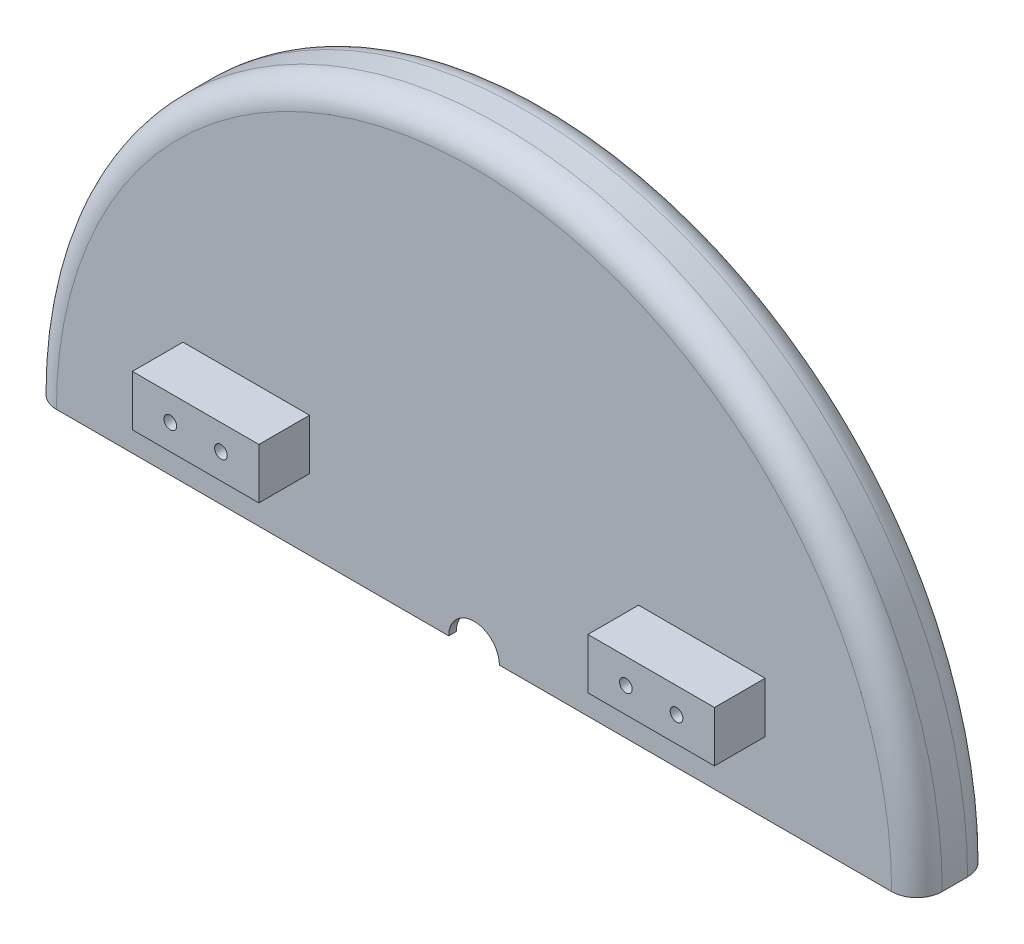
from build123d import *

# Parameters (mm, degrees)
SKETCH1_R                    = 175
BOSS_EXTRUDE3_DEPTH          = 30
CUT_EXTRUDE1_DEPTH           = 50
SHELL2_T                     = -3
SKETCH4_R                    = 10
CUT_EXTRUDE2_DEPTH           = 50
FILLET1_R                    = 10
SKETCH6_R                    = 50
CUT_EXTRUDE4_DEPTH           = 10
SKETCH9_W                    = 50
SKETCH9_H                    = 20
BOSS_EXTRUDE4_DEPTH          = 20
F_5_0_5_DIAMETER_HOLE2_D     = 5
F_5_0_5_DIAMETER_HOLE2_DEPTH = 11
F_5_0_5_DIAMETER_HOLE2_TIP   = 1.502151548


with BuildPart() as part:
    # Sketch1 → Boss-Extrude3 (new body)
    with BuildSketch(Plane.XY):
        Circle(SKETCH1_R)
    extrude(amount=BOSS_EXTRUDE3_DEPTH)

    # Sketch3 → Cut-Extrude1 (cut)
    with BuildSketch(Plane.XY.offset(30)):
        with BuildLine():
            Line((-175, 0), (175, 0))
            ThreePointArc((175, 0), (0, -175), (-175, 0))
        make_face()
    extrude(amount=-CUT_EXTRUDE1_DEPTH, mode=Mode.SUBTRACT)

    # Shell2
    shell2_openings = [part.faces().sort_by_distance(p)[0] for p in [
        (0, 0, 15),
    ]]
    offset(amount=SHELL2_T, openings=shell2_openings)

    # Sketch4 → Cut-Extrude2 (cut)
    with BuildSketch(Plane.XY.offset(30)):
        Circle(SKETCH4_R)
    extrude(amount=-CUT_EXTRUDE2_DEPTH, mode=Mode.SUBTRACT)

    # Fillet1
    fillet1_edges = [part.edges().sort_by_distance(p)[0] for p in [
        (0, 175, 0),
        (0, 175, 30),
    ]]
    fillet(fillet1_edges, radius=FILLET1_R)

    # Sketch6 → Cut-Extrude4 (cut)
    with BuildSketch(Plane(origin=(0, 0, 0), x_dir=(-1, 0, 0), z_dir=(0, 0, -1))):
        Circle(SKETCH6_R)
    extrude(amount=-CUT_EXTRUDE4_DEPTH, mode=Mode.SUBTRACT)

    # Sketch9 → Boss-Extrude4 (add)
    with BuildSketch(Plane.XY.offset(30)):
        with Locations((-90, 38)):
            Rectangle(SKETCH9_W, SKETCH9_H)
    boss_extrude4 = extrude(amount=BOSS_EXTRUDE4_DEPTH)

    # Mirror2: Boss-Extrude4 across plane
    add(boss_extrude4.mirror(Plane(origin=(0, 0, 0), x_dir=(0, 0, 1), z_dir=(1, 0, 0))))

    # Ø5.0 (5) Diameter Hole2
    with Locations(Plane.XY.offset(50)):
        with Locations((-100, 38), (-80, 38), (80, 38), (100, 38)):
            Hole(F_5_0_5_DIAMETER_HOLE2_D / 2, depth=F_5_0_5_DIAMETER_HOLE2_DEPTH)
            with Locations((0, 0, -(F_5_0_5_DIAMETER_HOLE2_DEPTH + F_5_0_5_DIAMETER_HOLE2_TIP / 2))):  # 118° drill point
                Cone(0, F_5_0_5_DIAMETER_HOLE2_D / 2, F_5_0_5_DIAMETER_HOLE2_TIP, mode=Mode.SUBTRACT)


solid = part.part
